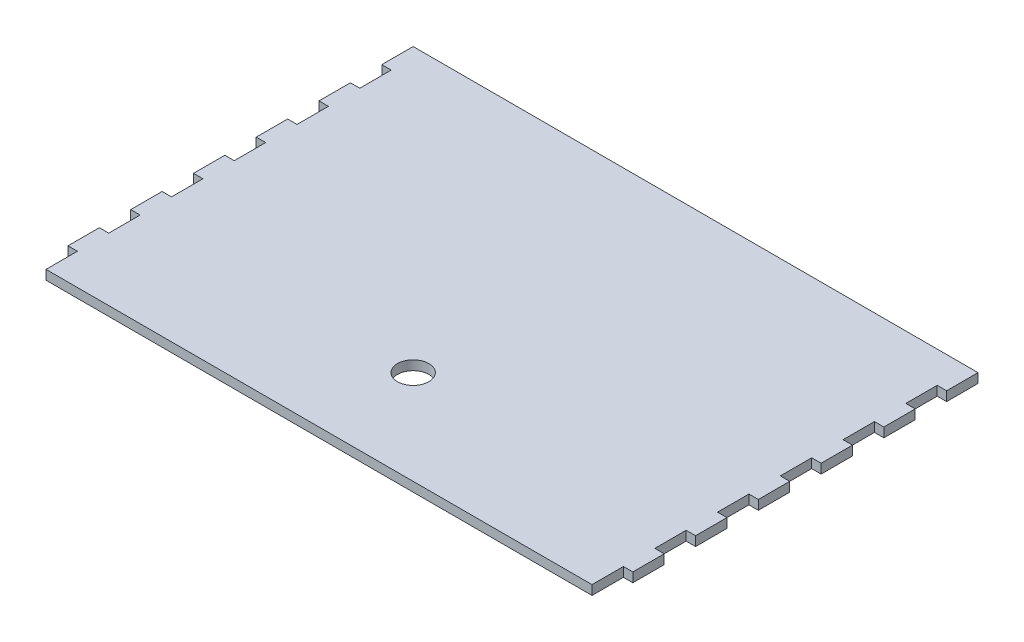
from build123d import *

# Parameters (mm, degrees)
ESQUISSE1_R        = 5
BOSS_EXTRU_1_DEPTH = 3


with BuildPart() as part:
    # Esquisse1 → Boss.-Extru.1 (new body)
    with BuildSketch(Plane(origin=(0, 0, 0), x_dir=(1, 0, 0), z_dir=(0, 1, 0))):
        Polygon((-90, 60), (90, 60), (90, 50), (87, 50), (87, 40), (90, 40), (90, 30), (87, 30), (87, 20), (90, 20), (90, 10), (87, 10), (87, 0), (90, 0), (90, -10), (87, -10), (87, -20), (90, -20), (90, -30), (87, -30), (87, -40), (90, -40), (90, -50), (87, -50), (87, -60), (-87, -60), (-87, -50), (-90, -50), (-90, -40), (-87, -40), (-87, -30), (-90, -30), (-90, -20), (-87, -20), (-87, -10), (-90, -10), (-90, 0), (-87, 0), (-87, 10), (-90, 10), (-90, 20), (-87, 20), (-87, 30), (-90, 30), (-90, 40), (-87, 40), (-87, 50), (-90, 50), align=None)
        with Locations((0, -30)):
            Circle(ESQUISSE1_R, mode=Mode.SUBTRACT)
    extrude(amount=BOSS_EXTRU_1_DEPTH)


solid = part.part
